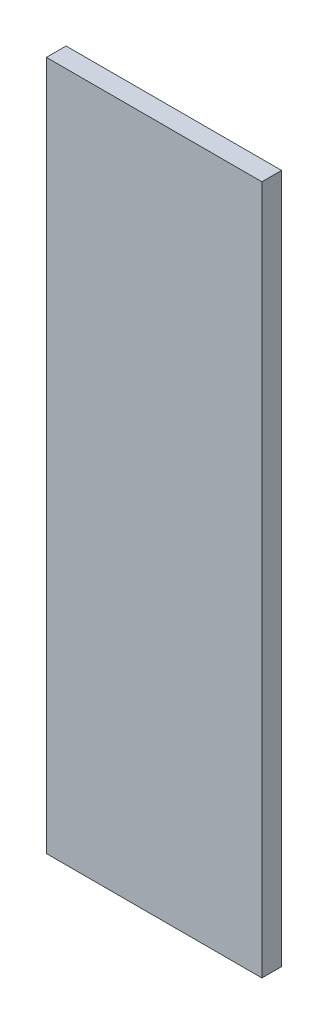
from build123d import *

# Parameters (mm, degrees)
SKETCH1_W           = 69.5
SKETCH1_H           = 222.4
BOSS_EXTRUDE1_DEPTH = 6.35


with BuildPart() as part:
    # Sketch1 → Boss-Extrude1 (new body)
    with BuildSketch(Plane.XY):
        with Locations((392.414513316, -20.578658451)):
            Rectangle(SKETCH1_W, SKETCH1_H)
    extrude(amount=-BOSS_EXTRUDE1_DEPTH)


solid = part.part
